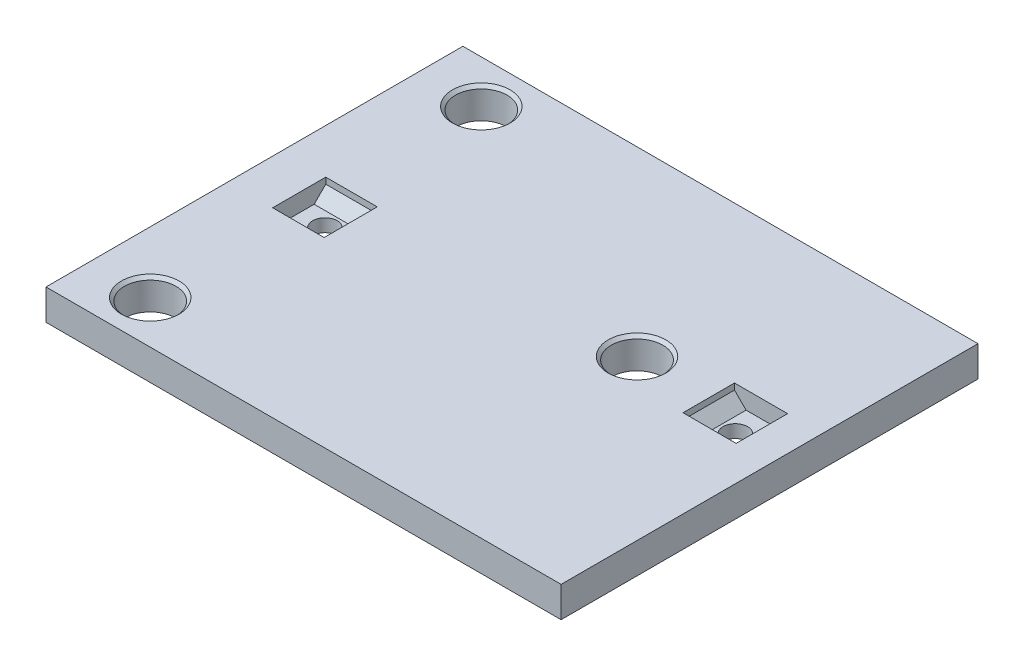
from build123d import *

# Parameters (mm, degrees)
SKETCH1_R               = 2.54
BOSS_EXTRUDE1_DEPTH     = 6.35
CUT_EXTRUDE1_DEPTH      = 5.334
CUT_EXTRUDE1_DEPTH_BACK = 5.334
CUT_EXTRUDE2_DEPTH      = 5.334
CUT_EXTRUDE2_DEPTH_BACK = 5.334
SKETCH6_R               = 5.334
CUT_EXTRUDE3_DEPTH      = 7.35
CHAMFER1_SIZE           = 0.635


with BuildPart() as part:
    # Sketch1 → Boss-Extrude1 (new body)
    with BuildSketch(Plane(origin=(0, 0, 0), x_dir=(1, 0, 0), z_dir=(0, 1, 0))):
        Polygon((0, 33.02), (0, 0), (22.86, 0), (106.700989027, 0), (106.700989027, 38.586695169), (106.700989027, 56.366695169), (106.700989027, 86.36), (20.32, 86.36), (0, 86.36), (0, 53.34), align=None)
        with Locations((14.605, 43.18)):
            Circle(SKETCH1_R, mode=Mode.SUBTRACT)
        with Locations((94.039183737, 48.746695169)):
            Circle(SKETCH1_R, mode=Mode.SUBTRACT)
    extrude(amount=BOSS_EXTRUDE1_DEPTH)

    # Sketch4 → Cut-Extrude1 (cut, two sides)
    with BuildSketch(Plane.ZY.offset(-14.605)) as cut_extrude1_sk:
        Polygon((-46.28, 2.68), (-40.08, 2.68), (-37.68, 5.08), (-37.68, 6.35), (-48.68, 6.35), (-48.68, 5.08), align=None)
    extrude(amount=CUT_EXTRUDE1_DEPTH, mode=Mode.SUBTRACT)
    extrude(cut_extrude1_sk.sketch, amount=-CUT_EXTRUDE1_DEPTH_BACK, mode=Mode.SUBTRACT)

    # Sketch5 → Cut-Extrude2 (cut, two sides)
    with BuildSketch(Plane.XY.offset(-48.746695169)) as cut_extrude2_sk:
        Polygon((90.939183737, 2.68), (97.139183737, 2.68), (99.539183737, 5.08), (99.539183737, 6.35), (88.539183737, 6.35), (88.539183737, 5.08), align=None)
    extrude(amount=CUT_EXTRUDE2_DEPTH, mode=Mode.SUBTRACT)
    extrude(cut_extrude2_sk.sketch, amount=-CUT_EXTRUDE2_DEPTH_BACK, mode=Mode.SUBTRACT)

    # Sketch6 → Cut-Extrude3 (cut, through all)
    with BuildSketch(Plane.XZ):
        with Locations((12.7, -8.89)):
            Circle(SKETCH6_R)
        with Locations((73.680989027, -48.746695169)):
            Circle(SKETCH6_R)
        with Locations((12.7, -77.47)):
            Circle(SKETCH6_R)
    extrude(amount=-CUT_EXTRUDE3_DEPTH, mode=Mode.SUBTRACT)

    # Chamfer1
    chamfer1_edges = [part.edges().sort_by_distance(p)[0] for p in [
        (7.366, 6.35, -8.89),
        (68.346989027, 6.35, -48.746695169),
        (7.366, 6.35, -77.47),
    ]]
    chamfer(chamfer1_edges, length=CHAMFER1_SIZE)


solid = part.part
